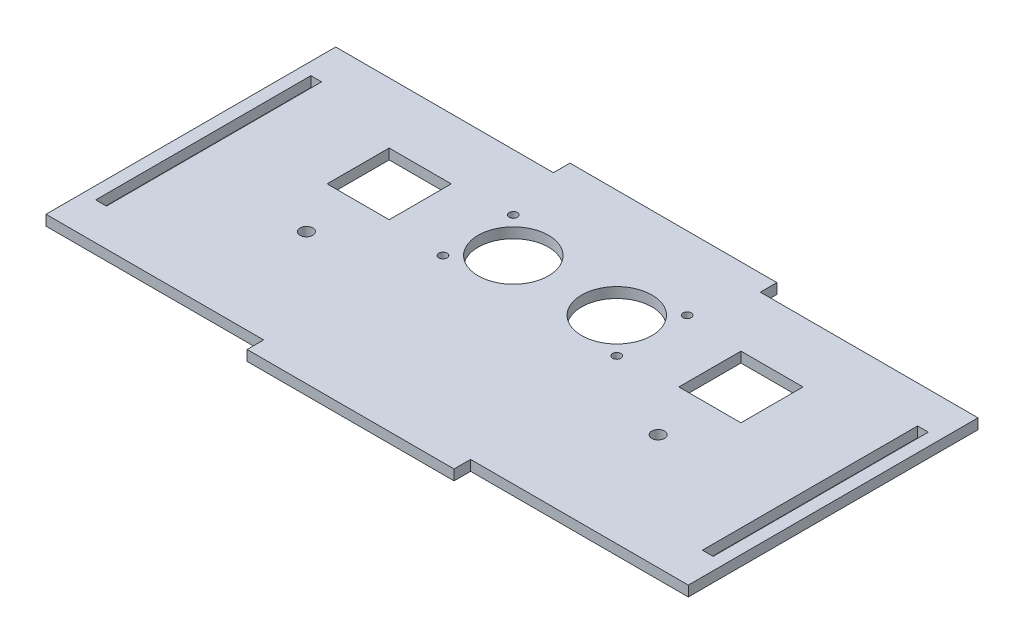
from build123d import *

# Parameters (mm, degrees)
SKETCH2_R           = 8.5
SKETCH2_R_2         = 1
SKETCH2_R_3         = 1.55
SKETCH2_W           = 2.6
SKETCH2_H           = 52
SKETCH2_W_2         = 15
SKETCH2_H_2         = 15
BOSS_EXTRUDE1_DEPTH = 2.5


with BuildPart() as part:
    # Sketch2 → Boss-Extrude1 (new body)
    with BuildSketch(Plane(origin=(0, 0, 0), x_dir=(1, 0, 0), z_dir=(0, 1, 0))):
        Polygon((-25, 35), (-77.6, 35), (-77.6, -35), (-25, -35), (-25, -39), (25, -39), (25, -35), (77.6, -35), (77.6, 35), (25, 35), (25, 39), (-25, 39), align=None)
        with Locations((-12.5, 12.818198975)):
            Circle(SKETCH2_R, mode=Mode.SUBTRACT)
        with Locations((-21, 21.318198975)):
            Circle(SKETCH2_R_2, mode=Mode.SUBTRACT)
        with Locations((-21, 4.318198975)):
            Circle(SKETCH2_R_2, mode=Mode.SUBTRACT)
        with Locations((21, 4.318198975)):
            Circle(SKETCH2_R_2, mode=Mode.SUBTRACT)
        with Locations((21, 21.318198975)):
            Circle(SKETCH2_R_2, mode=Mode.SUBTRACT)
        with Locations((12.5, 12.818198975)):
            Circle(SKETCH2_R, mode=Mode.SUBTRACT)
        with Locations((-42.5, -7.181801025)):
            Circle(SKETCH2_R_3, mode=Mode.SUBTRACT)
        with Locations((42.5, -7.181801025)):
            Circle(SKETCH2_R_3, mode=Mode.SUBTRACT)
        with Locations((-73.3, 0)):
            Rectangle(SKETCH2_W, SKETCH2_H, mode=Mode.SUBTRACT)
        with Locations((73.3, 0)):
            Rectangle(SKETCH2_W, SKETCH2_H, mode=Mode.SUBTRACT)
        with Locations((42.5, 12.818198975)):
            Rectangle(SKETCH2_W_2, SKETCH2_H_2, mode=Mode.SUBTRACT)
        with Locations((-42.5, 12.818198975)):
            Rectangle(SKETCH2_W_2, SKETCH2_H_2, mode=Mode.SUBTRACT)
    extrude(amount=BOSS_EXTRUDE1_DEPTH)


solid = part.part
